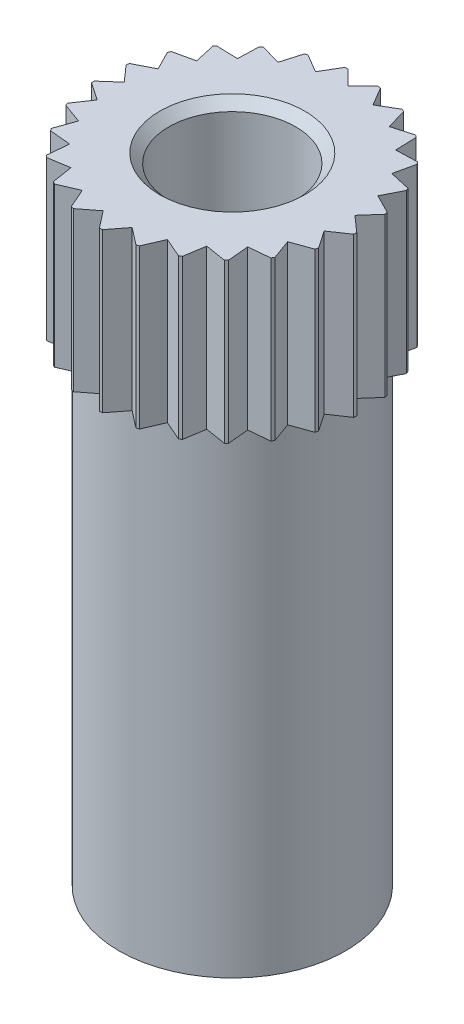
from build123d import *

# Parameters (mm, degrees)
SKETCH_1_R                  = 2.9
EXTRUDE_1_DEPTH             = 3.5
SKETCH_2_R                  = 2.5
EXTRUDE_2_DEPTH             = 10.5
CUT_EXTRUDE_1_DEPTH         = 4
HOLE_WIZARD_M32_D           = 2.8
HOLE_WIZARD_M32_DEPTH       = 6
HOLE_WIZARD_M32_CSINK_D     = 3.2
HOLE_WIZARD_M32_CSINK_ANGLE = 90
HOLE_WIZARD_M32_TIP         = 1.4


with BuildPart() as part:
    # Эскиз1 → Бобышка-Вытянуть1 (new body)
    with BuildSketch(Plane(origin=(0, 0, 0), x_dir=(1, 0, 0), z_dir=(0, 1, 0))):
        Circle(SKETCH_1_R)
    extrude(amount=EXTRUDE_1_DEPTH)

    # Эскиз2 → Бобышка-Вытянуть2 (add)
    with BuildSketch(Plane.XZ):
        Circle(SKETCH_2_R)
    extrude(amount=EXTRUDE_2_DEPTH)

    # Эскиз3 → Вырез-Вытянуть1 (cut)
    with BuildSketch(Plane(origin=(0, 3.5, 0), x_dir=(1, 0, 0), z_dir=(0, 1, 0))):
        Polygon((0, 2.55), (-0.366495157, 2.916495157), (0.366495157, 2.916495157), align=None)
        Polygon((0.634159212, 2.469887061), (0.370321814, 2.916011738), (1.080283889, 2.733724459), align=None)
        Polygon((1.228471869, 2.234582034), (1.083870103, 2.732304577), (1.726194412, 2.3791838), align=None)
        Polygon((1.74559512, 1.85887), (1.729314848, 2.37691667), (2.263641791, 1.875150272), align=None)
        Polygon((2.15303621, 1.366358327), (2.26610038, 1.872178348), (2.658856231, 1.253294157), align=None)
        Polygon((2.425194117, 0.787993336), (2.660498492, 1.249804175), (2.887004956, 0.55268896), align=None)
        Polygon((2.544968157, 0.160115825), (2.887727699, 0.548900209), (2.933752541, -0.182643716), align=None)
        Polygon((2.504832489, -0.477822352), (2.933510354, -0.186493176), (2.796161665, -0.906500217), align=None)
        Polygon((2.307308984, -1.085737193), (2.794969765, -0.910168509), (2.482877668, -1.573397974), align=None)
        Polygon((1.964808769, -1.625431174), (2.480810946, -1.576654607), (2.013585336, -2.141433351), align=None)
        Polygon((1.498852393, -2.062993336), (2.010773652, -2.144073698), (1.417772031, -2.574914594), align=None)
        Polygon((0.938717609, -2.370930039), (1.414392054, -2.576772752), (0.732874896, -2.846604484), align=None)
        Polygon((0.319599746, -2.529892488), (0.729139002, -2.847563698), (0.001928536, -2.939431745), align=None)
        Polygon((-0.319599746, -2.529892488), (-0.001928536, -2.939431745), (-0.729139002, -2.847563698), align=None)
        Polygon((-0.938717609, -2.370930039), (-0.732874896, -2.846604484), (-1.414392054, -2.576772752), align=None)
        Polygon((-1.498852393, -2.062993336), (-1.417772031, -2.574914594), (-2.010773652, -2.144073698), align=None)
        Polygon((-1.964808769, -1.625431174), (-2.013585336, -2.141433351), (-2.480810946, -1.576654607), align=None)
        Polygon((-2.307308984, -1.085737193), (-2.482877668, -1.573397974), (-2.794969765, -0.910168509), align=None)
        Polygon((-2.504832489, -0.477822352), (-2.796161665, -0.906500217), (-2.933510354, -0.186493176), align=None)
        Polygon((-2.544968157, 0.160115825), (-2.933752541, -0.182643716), (-2.887727699, 0.548900209), align=None)
        Polygon((-2.425194117, 0.787993336), (-2.887004956, 0.55268896), (-2.660498492, 1.249804175), align=None)
        Polygon((-2.15303621, 1.366358327), (-2.658856231, 1.253294157), (-2.26610038, 1.872178348), align=None)
        Polygon((-1.74559512, 1.85887), (-2.263641791, 1.875150272), (-1.729314848, 2.37691667), align=None)
        Polygon((-1.228471869, 2.234582034), (-1.726194412, 2.3791838), (-1.083870103, 2.732304577), align=None)
        Polygon((-0.634159212, 2.469887061), (-1.080283889, 2.733724459), (-0.370321814, 2.916011738), align=None)
    extrude(amount=-CUT_EXTRUDE_1_DEPTH, mode=Mode.SUBTRACT)

    # Сверло под метчик  спиральное M32
    with Locations(Plane(origin=(0, 3.5, 0), x_dir=(1, 0, 0), z_dir=(0, 1, 0))):
        with Locations((0, 0)):
            CounterSinkHole(HOLE_WIZARD_M32_D / 2, HOLE_WIZARD_M32_CSINK_D / 2, depth=HOLE_WIZARD_M32_DEPTH, counter_sink_angle=HOLE_WIZARD_M32_CSINK_ANGLE)
            with Locations((0, 0, -(HOLE_WIZARD_M32_DEPTH + HOLE_WIZARD_M32_TIP / 2))):  # 90° drill point
                Cone(0, HOLE_WIZARD_M32_D / 2, HOLE_WIZARD_M32_TIP, mode=Mode.SUBTRACT)


solid = part.part
